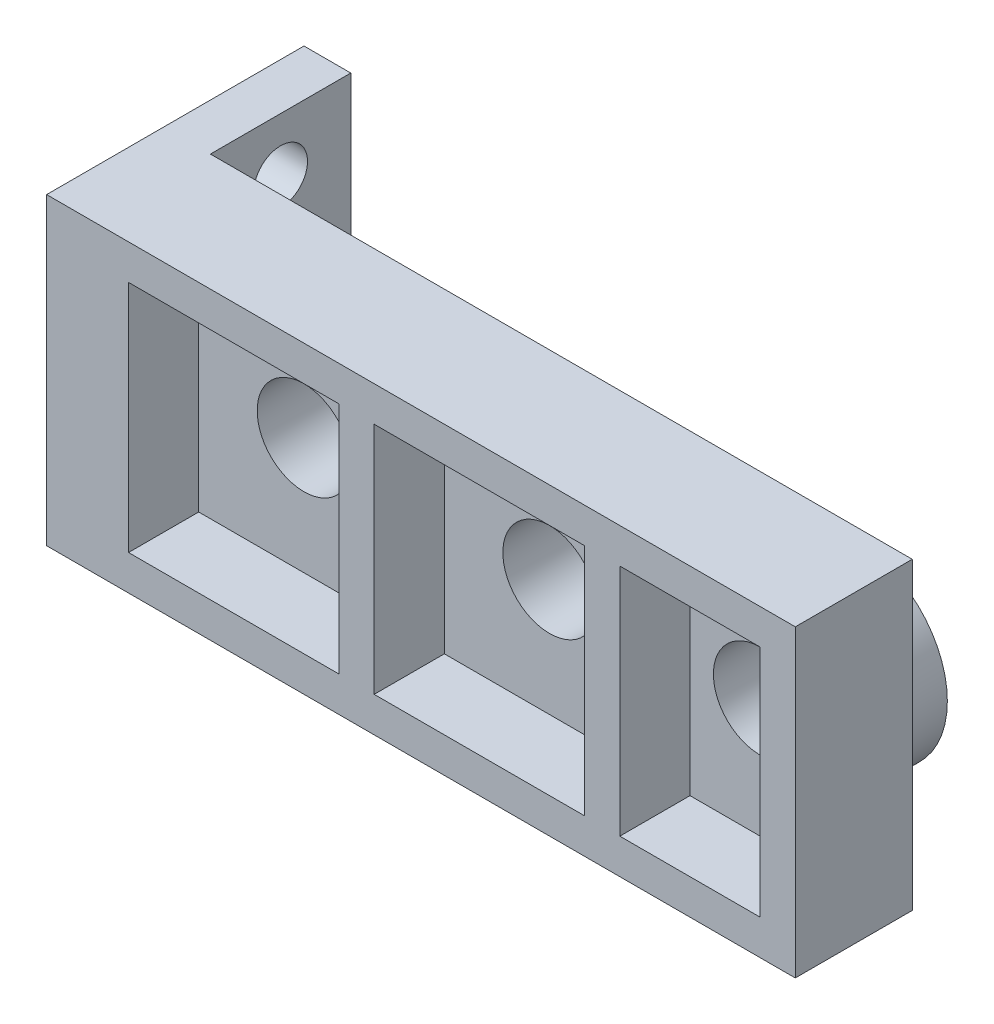
from build123d import *

# Parameters (mm, degrees)
SKETCH1_W           = 30
SKETCH1_H           = 13
BOSS_EXTRUDE1_DEPTH = 5
SKETCH2_W           = 9
SKETCH2_H           = 10
SKETCH2_W_2         = 6
CUT_EXTRUDE1_DEPTH  = 3
SKETCH3_R           = 2
CUT_EXTRUDE2_DEPTH  = 5
SKETCH4_W           = 11
SKETCH4_H           = 13
BOSS_EXTRUDE2_DEPTH = 2
SKETCH5_R           = 1.15
CUT_EXTRUDE3_DEPTH  = 2
SKETCH6_R           = 4
SKETCH6_R_2         = 2
BOSS_EXTRUDE3_DEPTH = 2


with BuildPart() as part:
    # Sketch1 → Boss-Extrude1 (new body)
    with BuildSketch(Plane.XY):
        Rectangle(SKETCH1_W, SKETCH1_H)
    extrude(amount=BOSS_EXTRUDE1_DEPTH)

    # Sketch2 → Cut-Extrude1 (cut)
    with BuildSketch(Plane.XY.offset(5)):
        with Locations((-9, 0)):
            Rectangle(SKETCH2_W, SKETCH2_H)
        with Locations((1.5, 0)):
            Rectangle(SKETCH2_W, SKETCH2_H)
        with Locations((10.5, 0)):
            Rectangle(SKETCH2_W_2, SKETCH2_H)
    extrude(amount=-CUT_EXTRUDE1_DEPTH, mode=Mode.SUBTRACT)

    # Sketch3 → Cut-Extrude2 (cut)
    with BuildSketch(Plane.XY.offset(2)):
        with Locations((-9, 0)):
            Circle(SKETCH3_R)
        with Locations((1.5, 0)):
            Circle(SKETCH3_R)
        with Locations((10.5, 0)):
            Circle(SKETCH3_R)
    extrude(amount=-CUT_EXTRUDE2_DEPTH, mode=Mode.SUBTRACT)

    # Sketch4 → Boss-Extrude2 (add)
    with BuildSketch(Plane.ZY.offset(15)):
        with Locations((-0.5, 0)):
            Rectangle(SKETCH4_W, SKETCH4_H)
    extrude(amount=BOSS_EXTRUDE2_DEPTH)

    # Sketch5 → Cut-Extrude3 (cut)
    with BuildSketch(Plane(origin=(-15, 0, 0), x_dir=(0, 0, -1), z_dir=(1, 0, 0))):
        with Locations((3, 4.158153832)):
            Circle(SKETCH5_R)
        with Locations((3, -2.579108073)):
            Circle(SKETCH5_R)
    extrude(amount=-CUT_EXTRUDE3_DEPTH, mode=Mode.SUBTRACT)

    # Sketch6 → Boss-Extrude3 (add)
    with BuildSketch(Plane(origin=(0, 0, 0), x_dir=(-1, 0, 0), z_dir=(0, 0, -1))):
        with Locations(Location((-10.5, 0, 0), (0, 0, 180))):
            Circle(SKETCH6_R)
        with Locations(Location((-10.5, 0, 0), (0, 0, 180))):
            Circle(SKETCH6_R_2, mode=Mode.SUBTRACT)
        with Locations(Location((-1.5, 0, 0), (0, 0, 180))):
            Circle(SKETCH6_R)
        with Locations(Location((-1.5, 0, 0), (0, 0, 180))):
            Circle(SKETCH6_R_2, mode=Mode.SUBTRACT)
        with Locations(Location((9, 0, 0), (0, 0, 180))):
            Circle(SKETCH6_R)
        with Locations(Location((9, 0, 0), (0, 0, 180))):
            Circle(SKETCH6_R_2, mode=Mode.SUBTRACT)
    extrude(amount=BOSS_EXTRUDE3_DEPTH)


solid = part.part
